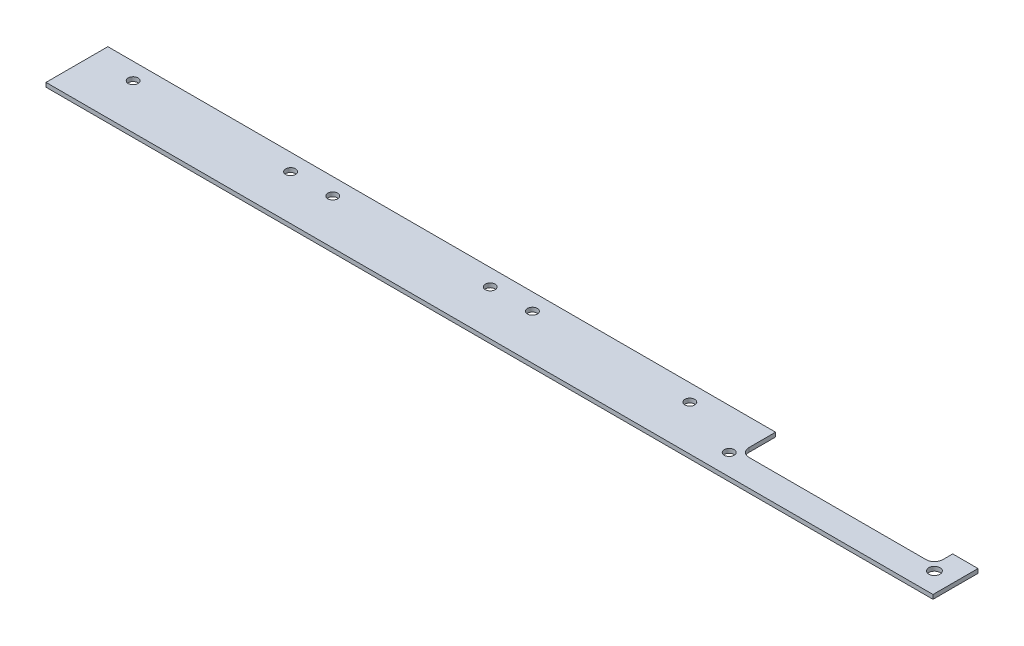
from build123d import *

# Parameters (mm, degrees)
SKETCH_1_R      = 1.75
SKETCH_1_R_2    = 2
EXTRUDE_1_DEPTH = 1.5


with BuildPart() as part:
    # Эскиз1 → Бобышка-Вытянуть1 (new body)
    with BuildSketch(Plane(origin=(0, 0, 0), x_dir=(1, 0, 0), z_dir=(0, 1, 0))):
        with BuildLine():
            Line((237.5, 12.5), (237.5, 22))
            Line((237.5, 22), (0, 22))
            Line((0, 22), (0, 0))
            Line((0, 0), (315.5, 0))
            Line((315.5, 0), (315.5, 16))
            Line((315.5, 16), (306.5, 16))
            Line((306.5, 16), (306.5, 12.5))
            ThreePointArc((306.5, 12.5), (305.621320344, 10.378679656), (303.5, 9.5))
            Line((303.5, 9.5), (240.5, 9.5))
            ThreePointArc((240.5, 9.5), (238.378679656, 10.378679656), (237.5, 12.5))
        make_face()
        with Locations((235.5, 7.5)):
            Circle(SKETCH_1_R, mode=Mode.SUBTRACT)
        with Locations((308.5, 7.5)):
            Circle(SKETCH_1_R_2, mode=Mode.SUBTRACT)
        with Locations((15, 16)):
            Circle(SKETCH_1_R, mode=Mode.SUBTRACT)
        with Locations((71, 16)):
            Circle(SKETCH_1_R, mode=Mode.SUBTRACT)
        with Locations((86, 16)):
            Circle(SKETCH_1_R, mode=Mode.SUBTRACT)
        with Locations((142, 16)):
            Circle(SKETCH_1_R, mode=Mode.SUBTRACT)
        with Locations((157, 16)):
            Circle(SKETCH_1_R, mode=Mode.SUBTRACT)
        with Locations((213, 16)):
            Circle(SKETCH_1_R, mode=Mode.SUBTRACT)
    extrude(amount=EXTRUDE_1_DEPTH)


solid = part.part
